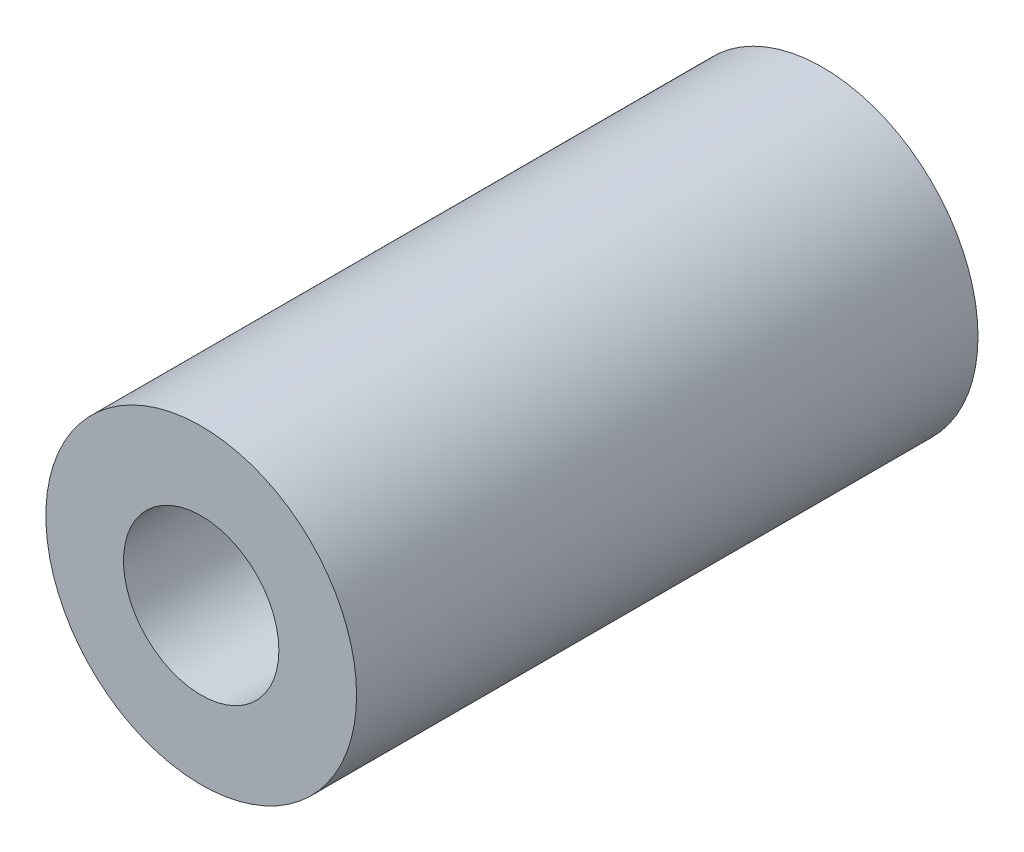
from build123d import *

# Parameters (mm, degrees)
SKETCH1_R           = 50
BOSS_EXTRUDE1_DEPTH = 200
SKETCH2_R           = 25
CUT_EXTRUDE1_DEPTH  = 201


with BuildPart() as part:
    # Sketch1 → Boss-Extrude1 (new body)
    with BuildSketch(Plane.XY):
        Circle(SKETCH1_R)
    extrude(amount=BOSS_EXTRUDE1_DEPTH)

    # Sketch2 → Cut-Extrude1 (cut, through all)
    with BuildSketch(Plane.XY.offset(200)):
        Circle(SKETCH2_R)
    extrude(amount=-CUT_EXTRUDE1_DEPTH, mode=Mode.SUBTRACT)


solid = part.part
